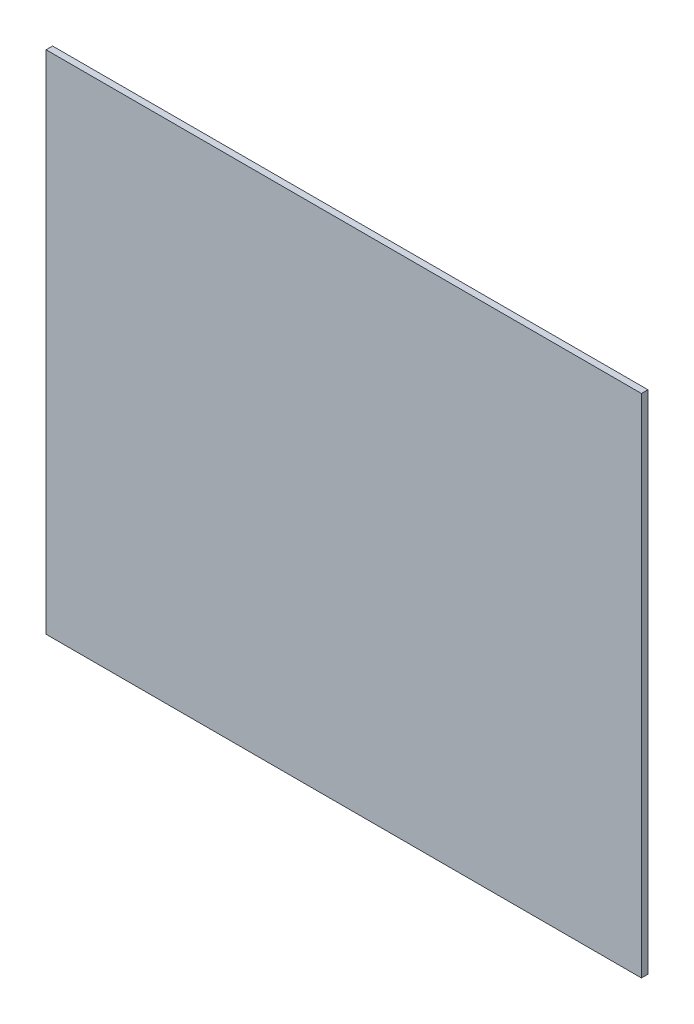
from build123d import *

# Parameters (mm, degrees)
SKETCH1_W           = 91.702857143
SKETCH1_H           = 77.973333333
BOSS_EXTRUDE1_DEPTH = 1


with BuildPart() as part:
    # Sketch1 → Boss-Extrude1 (new body)
    with BuildSketch(Plane.XY):
        with Locations((-1.295238096, 1.036190476)):
            Rectangle(SKETCH1_W, SKETCH1_H)
    extrude(amount=BOSS_EXTRUDE1_DEPTH)


solid = part.part
